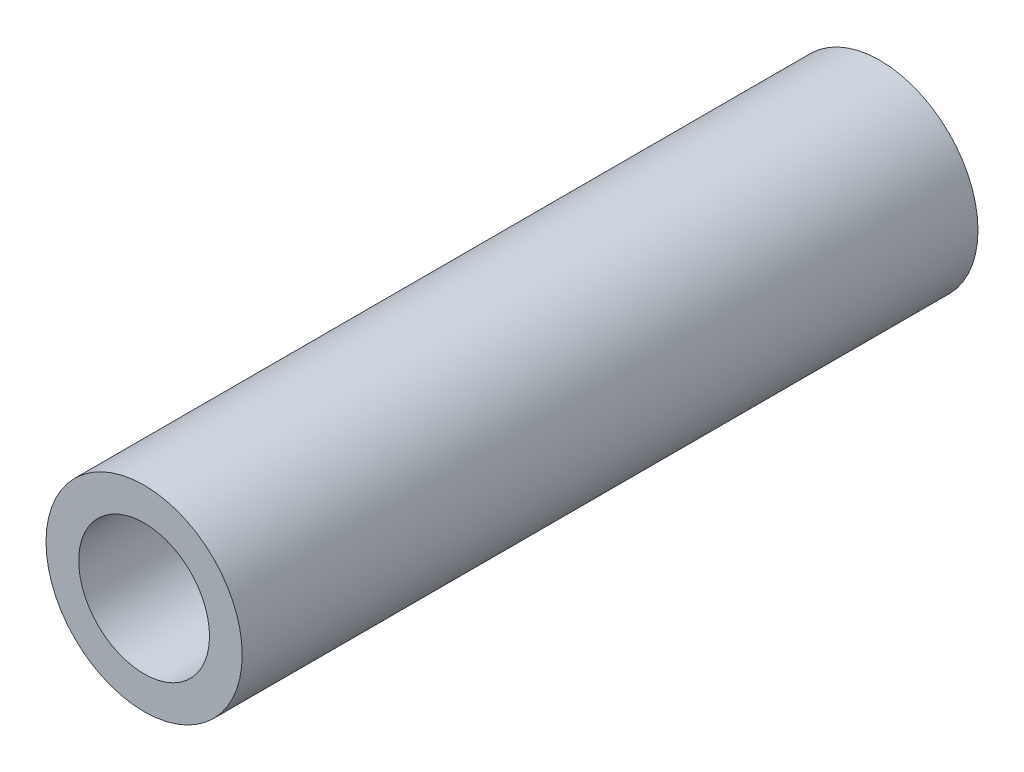
from build123d import *

# Parameters (mm, degrees)
SKETCH1_R           = 7.62
SKETCH1_R_2         = 5.08
BOSS_EXTRUDE1_DEPTH = 57.15


with BuildPart() as part:
    # Sketch1 → Boss-Extrude1 (new body)
    with BuildSketch(Plane.XY):
        Circle(SKETCH1_R)
        Circle(SKETCH1_R_2, mode=Mode.SUBTRACT)
    extrude(amount=BOSS_EXTRUDE1_DEPTH)


solid = part.part
